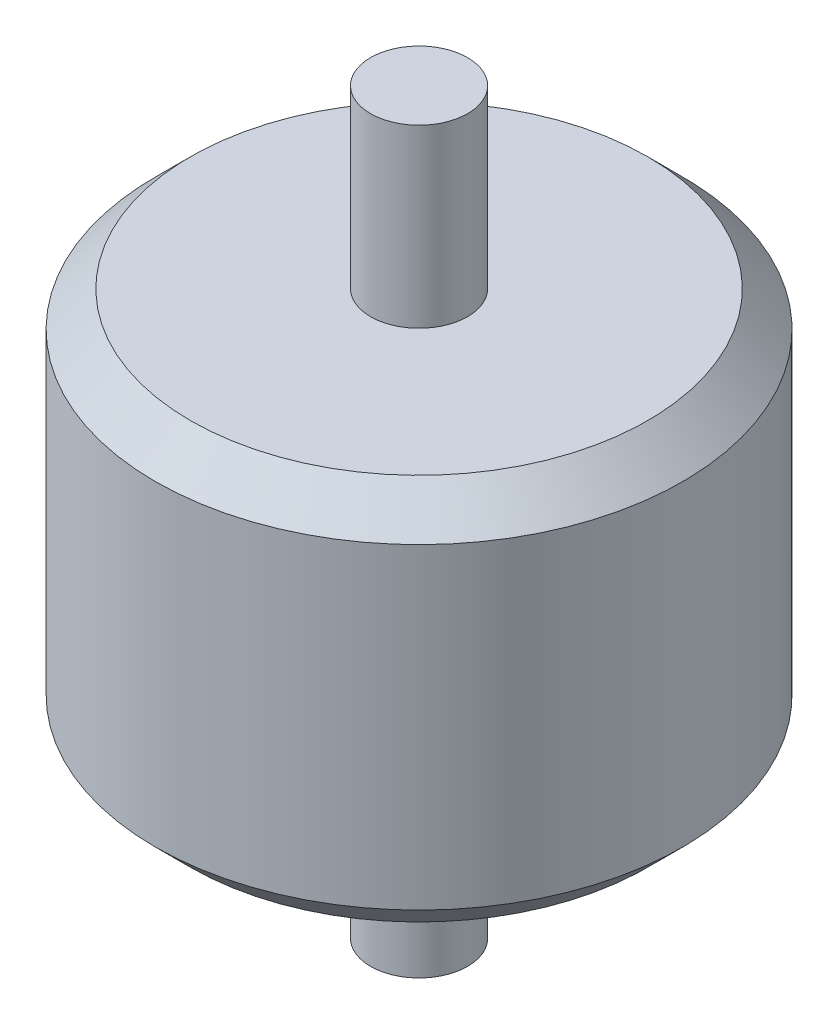
from build123d import *

# Parameters (mm, degrees)
SKETCH1_W   = 9.525
SKETCH1_H   = 11.43
SKETCH1_W_2 = 1.7526
SKETCH1_H_2 = 6.35


with BuildPart() as part:
    # Sketch1 → Revolve1 (revolve)
    with BuildSketch(Plane(origin=(0, 0, 0), x_dir=(0, 0, -1), z_dir=(1, 0, 0))):
        with Locations((4.7625, -5.715)):
            Rectangle(SKETCH1_W, SKETCH1_H)
        Polygon((1.27, 1.27), (0, 0), (9.525, 0), (9.525, 1.27), (7.7724, 1.27), align=None)
        with Locations((8.6487, 4.445)):
            Rectangle(SKETCH1_W_2, SKETCH1_H_2)
        Polygon((9.525, -11.43), (0, -11.43), (1.27, -12.7), (7.7724, -12.7), (9.525, -12.7), align=None)
        with Locations((8.6487, -15.875)):
            Rectangle(SKETCH1_W_2, SKETCH1_H_2)
    revolve(axis=Axis((0, 7.62, -9.525), (0, -1, 0)))


solid = part.part
